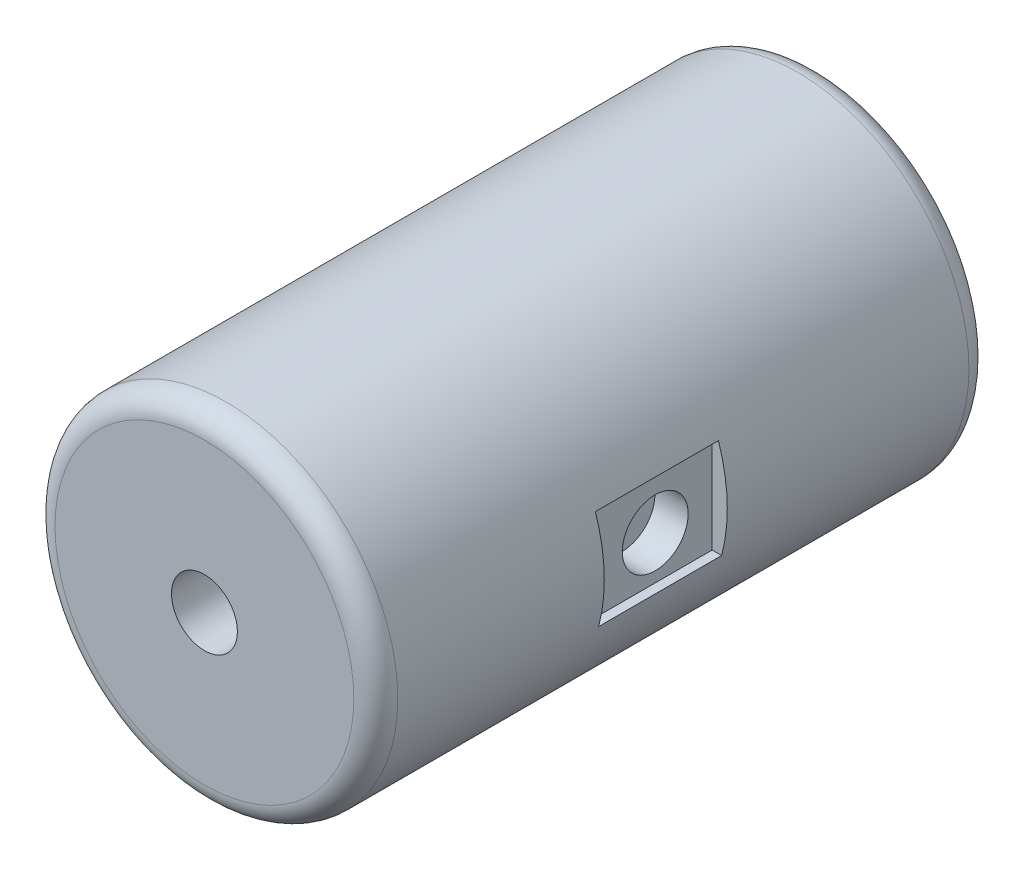
from build123d import *

# Parameters (mm, degrees)
SKETCH1_R           = 3.9
BOSS_EXTRUDE1_DEPTH = 14
FILLET1_R           = 0.5
SKETCH2_R           = 0.75
CUT_EXTRUDE2_DEPTH  = 5
SKETCH3_R           = 0.75
CUT_EXTRUDE3_DEPTH  = 5
SKETCH4_R           = 0.75
CUT_EXTRUDE4_DEPTH  = 1
SKETCH5_W           = 0.434986795
SKETCH5_H           = 2.227981147
CUT_EXTRUDE5_DEPTH  = 2.8


with BuildPart() as part:
    # Sketch1 → Boss-Extrude1 (new body)
    with BuildSketch(Plane.XY):
        Circle(SKETCH1_R)
    extrude(amount=BOSS_EXTRUDE1_DEPTH)

    # Fillet1
    fillet1_edges = [part.edges().sort_by_distance(p)[0] for p in [
        (-3.9, 0, 0),
        (-3.9, 0, 14),
    ]]
    fillet(fillet1_edges, radius=FILLET1_R)

    # Sketch2 → Cut-Extrude2 (cut)
    with BuildSketch(Plane.XY.offset(14)):
        Circle(SKETCH2_R)
    extrude(amount=-CUT_EXTRUDE2_DEPTH, mode=Mode.SUBTRACT)

    # Sketch3 → Cut-Extrude3 (cut)
    with BuildSketch(Plane(origin=(0, 0, 0), x_dir=(-1, 0, 0), z_dir=(0, 0, -1))):
        with Locations((0, 1.5)):
            Circle(SKETCH3_R)
        with Locations((0, -1.5)):
            Circle(SKETCH3_R)
    extrude(amount=-CUT_EXTRUDE3_DEPTH, mode=Mode.SUBTRACT)

    # Sketch4 → Cut-Extrude4 (cut, symmetric)
    with BuildSketch(Plane(origin=(-3.8, 0, 0), x_dir=(0, 0, -1), z_dir=(1, 0, 0))):
        with Locations((-7.297217633, 0)):
            Circle(SKETCH4_R)
    cut_extrude4 = extrude(amount=CUT_EXTRUDE4_DEPTH, both=True, mode=Mode.SUBTRACT)

    # Sketch5 → Cut-Extrude5 (cut)
    with BuildSketch(Plane.XY.offset(6)):
        with Locations((-3.774117143, 0.125124808)):
            Rectangle(SKETCH5_W, SKETCH5_H)
    cut_extrude5 = extrude(amount=CUT_EXTRUDE5_DEPTH, mode=Mode.SUBTRACT)

    # Mirror1: Cut-Extrude4, Cut-Extrude5 across plane
    add(cut_extrude4.mirror(Plane(origin=(0, 0, 0), x_dir=(0, 0, 1), z_dir=(1, 0, 0))), mode=Mode.SUBTRACT)
    add(cut_extrude5.mirror(Plane(origin=(0, 0, 0), x_dir=(0, 0, 1), z_dir=(1, 0, 0))), mode=Mode.SUBTRACT)


solid = part.part
